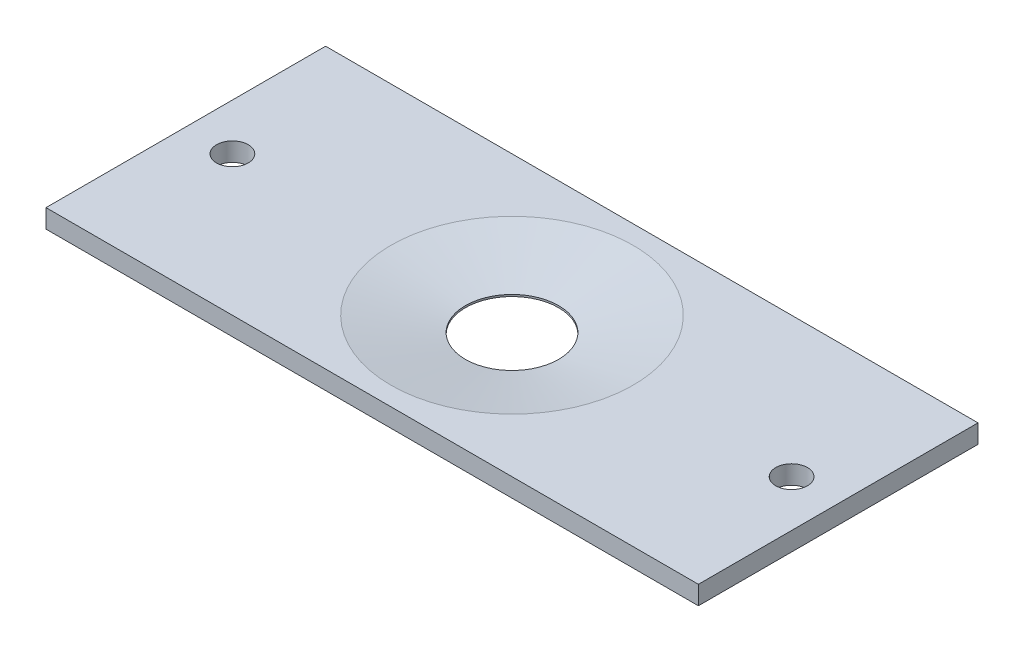
from build123d import *

# Parameters (mm, degrees)
SKETCH1_W            = 70
SKETCH1_H            = 30
SKETCH1_R            = 5
EXTRUDE1_DEPTH       = 2
CHAMFER1_SIZE        = 8
CHAMFER1_SIZE2       = 1.6
SKETCH3_R            = 5.5
CUT_EXTRUDE1_DEPTH   = 0.2
M3_CLEARANCE_HOLE1_D = 3.4


with BuildPart() as part:
    # Sketch1 → Extrude1 (new body)
    with BuildSketch(Plane(origin=(0, 0, 0), x_dir=(1, 0, 0), z_dir=(0, 1, 0))):
        Rectangle(SKETCH1_W, SKETCH1_H)
        Circle(SKETCH1_R, mode=Mode.SUBTRACT)
    extrude(amount=EXTRUDE1_DEPTH)

    # Chamfer1
    chamfer1_edges = [part.edges().sort_by_distance(p)[0] for p in [
        (-5, 2, 0),
    ]]
    chamfer1_side = [part.faces().sort_by_distance(p)[0] for p in [
        (0, 2, -14.238422689),
    ]]
    chamfer(chamfer1_edges, length=CHAMFER1_SIZE, length2=CHAMFER1_SIZE2, reference=chamfer1_side[0])

    # Sketch3 → Cut-Extrude1 (cut)
    with BuildSketch(Plane.XZ):
        Circle(SKETCH3_R)
    extrude(amount=-CUT_EXTRUDE1_DEPTH, mode=Mode.SUBTRACT)

    # M3 Clearance Hole1 (through all)
    with Locations(Plane(origin=(0, 2, 0), x_dir=(-1, 0, 0), z_dir=(0, 1, 0))):
        with Locations((-30, 0), (30, 0)):
            Hole(M3_CLEARANCE_HOLE1_D / 2)


solid = part.part
